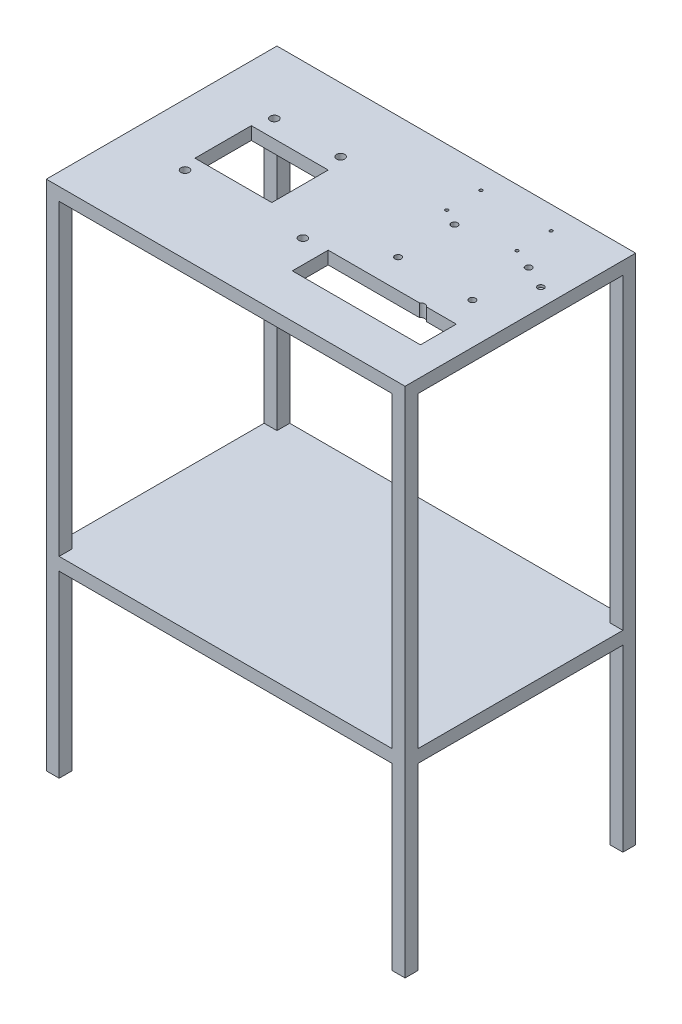
from build123d import *

# Parameters (mm, degrees)
SKETCH1_W               = 700
SKETCH1_H               = 450
BOSS_EXTRUDE1_DEPTH     = 1000
SKETCH2_W               = 650
SKETCH2_H               = 600
CUT_EXTRUDE1_DEPTH      = 250
CUT_EXTRUDE1_DEPTH_BACK = 250
SKETCH3_W               = 650
SKETCH3_H               = 350
CUT_EXTRUDE2_DEPTH      = 250
CUT_EXTRUDE2_DEPTH_BACK = 250
SKETCH4_W               = 400
SKETCH4_H               = 600
CUT_EXTRUDE3_DEPTH      = 400
CUT_EXTRUDE3_DEPTH_BACK = 400
SKETCH5_W               = 400
SKETCH5_H               = 350
CUT_EXTRUDE4_DEPTH      = 400
CUT_EXTRUDE4_DEPTH_BACK = 400
ESBO_O1_R               = 8
ESBO_O1_W               = 150
ESBO_O1_H               = 110
CORTE_EXTRUS_O1_DEPTH   = 50
ESBO_O2_W               = 250
ESBO_O2_H               = 70
CORTE_EXTRUS_O2_DEPTH   = 26
ESBO_O3_R               = 6.25
CORTE_EXTRUS_O3_DEPTH   = 10
ESBO_O5_R               = 3
CORTE_EXTRUS_O4_DEPTH   = 26
ESBO_O7_R               = 6
CORTE_EXTRUS_O5_DEPTH   = 5


with BuildPart() as part:
    # Sketch1 → Boss-Extrude1 (new body)
    with BuildSketch(Plane(origin=(0, 0, 0), x_dir=(1, 0, 0), z_dir=(0, 1, 0))):
        Rectangle(SKETCH1_W, SKETCH1_H)
    extrude(amount=BOSS_EXTRUDE1_DEPTH)

    # Sketch2 → Cut-Extrude1 (cut, two sides)
    with BuildSketch(Plane.XY) as cut_extrude1_sk:
        with Locations((0, 675)):
            Rectangle(SKETCH2_W, SKETCH2_H)
    extrude(amount=CUT_EXTRUDE1_DEPTH, mode=Mode.SUBTRACT)
    extrude(cut_extrude1_sk.sketch, amount=-CUT_EXTRUDE1_DEPTH_BACK, mode=Mode.SUBTRACT)

    # Sketch3 → Cut-Extrude2 (cut, two sides)
    with BuildSketch(Plane.XY) as cut_extrude2_sk:
        with Locations((0, 175)):
            Rectangle(SKETCH3_W, SKETCH3_H)
    extrude(amount=CUT_EXTRUDE2_DEPTH, mode=Mode.SUBTRACT)
    extrude(cut_extrude2_sk.sketch, amount=-CUT_EXTRUDE2_DEPTH_BACK, mode=Mode.SUBTRACT)

    # Sketch4 → Cut-Extrude3 (cut, two sides)
    with BuildSketch(Plane(origin=(0, 0, 0), x_dir=(0, 0, -1), z_dir=(1, 0, 0))) as cut_extrude3_sk:
        with Locations((0, 675)):
            Rectangle(SKETCH4_W, SKETCH4_H)
    extrude(amount=CUT_EXTRUDE3_DEPTH, mode=Mode.SUBTRACT)
    extrude(cut_extrude3_sk.sketch, amount=-CUT_EXTRUDE3_DEPTH_BACK, mode=Mode.SUBTRACT)

    # Sketch5 → Cut-Extrude4 (cut, two sides)
    with BuildSketch(Plane(origin=(0, 0, 0), x_dir=(0, 0, -1), z_dir=(1, 0, 0))) as cut_extrude4_sk:
        with Locations((0, 175)):
            Rectangle(SKETCH5_W, SKETCH5_H)
    extrude(amount=CUT_EXTRUDE4_DEPTH, mode=Mode.SUBTRACT)
    extrude(cut_extrude4_sk.sketch, amount=-CUT_EXTRUDE4_DEPTH_BACK, mode=Mode.SUBTRACT)

    # Esboço1 → Corte-extrusão1 (cut)
    with BuildSketch(Plane(origin=(0, 1000, 0), x_dir=(1, 0, 0), z_dir=(0, 1, 0))):
        with Locations((-100.84, 100)):
            Circle(ESBO_O1_R)
        with Locations((-230, 100)):
            Circle(ESBO_O1_R)
        with Locations((-230, -74.37)):
            Circle(ESBO_O1_R)
        with Locations((0, -74.37)):
            Circle(ESBO_O1_R)
        with Locations((230, -74.37)):
            Circle(ESBO_O1_R)
        with Locations((-165.42, 10.42)):
            Rectangle(ESBO_O1_W, ESBO_O1_H)
    extrude(amount=-CORTE_EXTRUS_O1_DEPTH, mode=Mode.SUBTRACT)

    # Esboço2 → Corte-extrusão2 (cut, through all)
    with BuildSketch(Plane(origin=(0, 975, 0), x_dir=(-1, 0, 0), z_dir=(0, -1, 0))):
        with Locations((-170, -105)):
            Rectangle(ESBO_O2_W, ESBO_O2_H)
    extrude(amount=-CORTE_EXTRUS_O2_DEPTH, mode=Mode.SUBTRACT)

    # Esboço3 → Corte-extrusão3 (cut)
    with BuildSketch(Plane(origin=(0, 1000, 0), x_dir=(1, 0, 0), z_dir=(0, 1, 0))):
        with Locations((270, -13.671274916)):
            Circle(ESBO_O3_R)
        with Locations((270, 96.328725084)):
            Circle(ESBO_O3_R)
        with Locations((125, 96.328725084)):
            Circle(ESBO_O3_R)
        with Locations((125, -13.671274916)):
            Circle(ESBO_O3_R)
    extrude(amount=-CORTE_EXTRUS_O3_DEPTH, mode=Mode.SUBTRACT)

    # Esboço5 → Corte-extrusão4 (cut, through all)
    with BuildSketch(Plane.XZ.offset(-975)):
        with Locations((93, -180)):
            Circle(ESBO_O5_R)
        with Locations((93, -113.3)):
            Circle(ESBO_O5_R)
        with Locations((230, -113.3)):
            Circle(ESBO_O5_R)
        with Locations((230, -180)):
            Circle(ESBO_O5_R)
    extrude(amount=-CORTE_EXTRUS_O4_DEPTH, mode=Mode.SUBTRACT)

    # Esboço7 → Corte-extrusão5 (cut)
    with BuildSketch(Plane(origin=(0, 1000, 0), x_dir=(1, 0, 0), z_dir=(0, 1, 0))):
        with Locations((315, 75)):
            Circle(ESBO_O7_R)
    extrude(amount=-CORTE_EXTRUS_O5_DEPTH, mode=Mode.SUBTRACT)


solid = part.part
